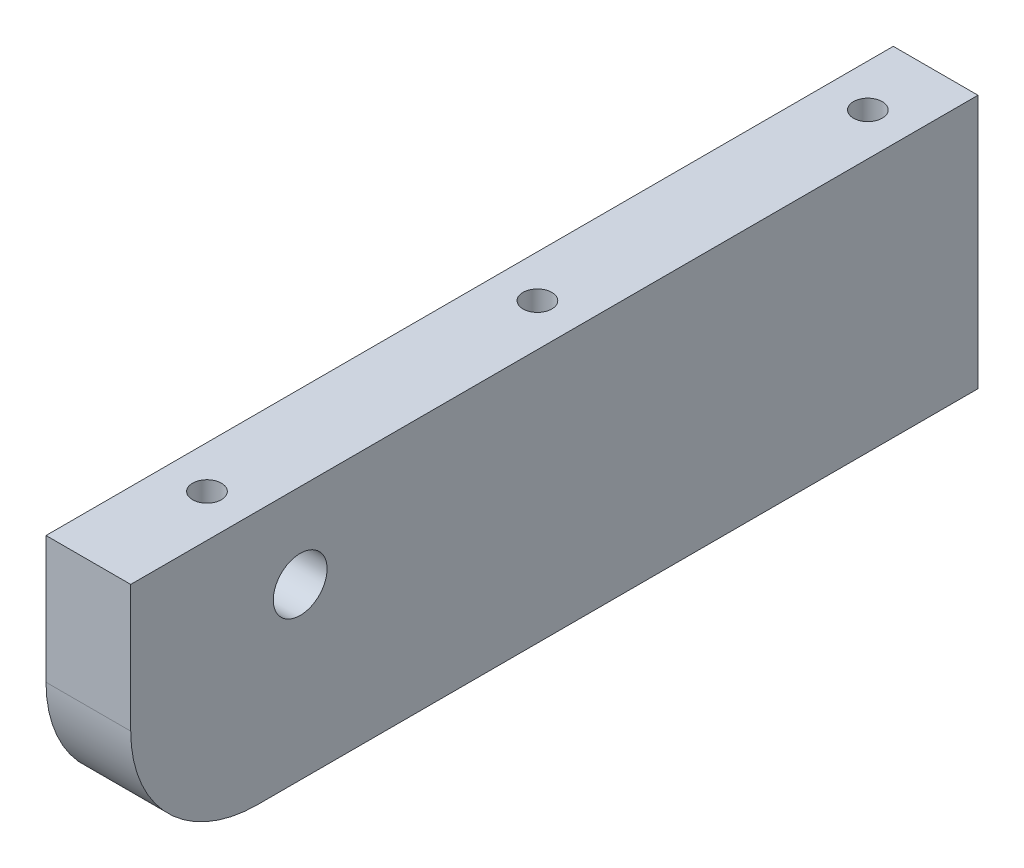
from build123d import *

# Parameters (mm, degrees)
SKETCH1_W                     = 100
SKETCH1_H                     = 30
SKETCH1_R                     = 3.175
BOSS_EXTRUDE1_DEPTH           = 10
FILLET1_R                     = 15
CBORE_FOR_M3_SHCS_D           = 3.4
CBORE_FOR_M3_SHCS_DEPTH       = 23
CBORE_FOR_M3_SHCS_CBORE_D     = 6.5
CBORE_FOR_M3_SHCS_CBORE_DEPTH = 3
CBORE_FOR_M3_SHCS_TIP         = 1.021463052


with BuildPart() as part:
    # Sketch1 → Boss-Extrude1 (new body)
    with BuildSketch(Plane(origin=(0, 0, 0), x_dir=(0, 0, -1), z_dir=(1, 0, 0))):
        Rectangle(SKETCH1_W, SKETCH1_H)
        with Locations((-30, 5)):
            Circle(SKETCH1_R, mode=Mode.SUBTRACT)
    extrude(amount=BOSS_EXTRUDE1_DEPTH)

    # Fillet1
    fillet1_edges = [part.edges().sort_by_distance(p)[0] for p in [
        (5, -15, 50),
    ]]
    fillet(fillet1_edges, radius=FILLET1_R)

    # CBORE for M3 SHCS
    with Locations(Plane(origin=(-726.293536786, 25, -1323.282701689), x_dir=(1, 0, 0), z_dir=(0, 1, 0))):
        with Locations((731.293536786, -1281.282701689), (731.293536786, -1359.282701689), (621.293536786, -1281.282701689), (621.293536786, -1365.282701689), (621.293536786, -1323.282701689), (731.293536786, -1320.282701689)):
            CounterBoreHole(CBORE_FOR_M3_SHCS_D / 2, CBORE_FOR_M3_SHCS_CBORE_D / 2, CBORE_FOR_M3_SHCS_CBORE_DEPTH, depth=CBORE_FOR_M3_SHCS_DEPTH)
            with Locations((0, 0, -(CBORE_FOR_M3_SHCS_DEPTH + CBORE_FOR_M3_SHCS_TIP / 2))):  # 118° drill point
                Cone(0, CBORE_FOR_M3_SHCS_D / 2, CBORE_FOR_M3_SHCS_TIP, mode=Mode.SUBTRACT)


solid = part.part
